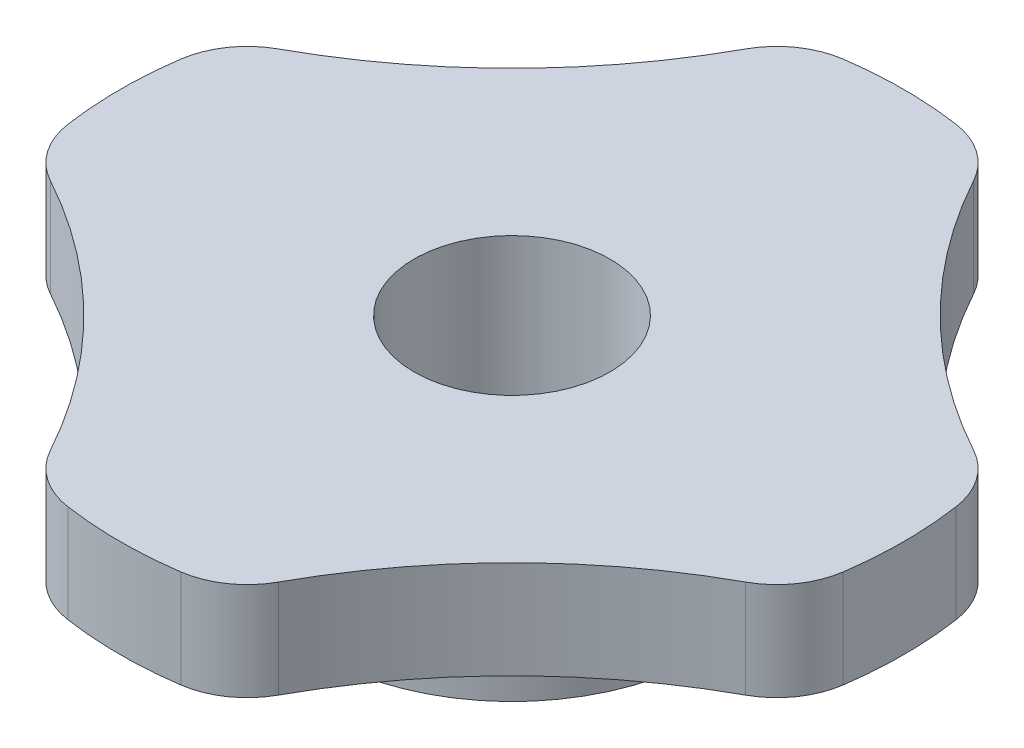
from build123d import *

# Parameters (mm, degrees)
SKETCH1_R           = 3.175
BOSS_EXTRUDE1_DEPTH = 3.175
BOSS_EXTRUDE2_START = -3.175
SKETCH1_3_R         = 3.175
BOSS_EXTRUDE2_DEPTH = 3.175
FILLET1_R           = 2.54


with BuildPart() as part:
    # Sketch1 → Boss-Extrude1 (new body)
    with BuildSketch(Plane(origin=(0, 0, 0), x_dir=(1, 0, 0), z_dir=(0, 1, 0))):
        with BuildLine():
            ThreePointArc((-3.175, 12.296722124), (-6.940246952, 6.940246952), (-12.296722124, 3.175))
            ThreePointArc((-12.296722124, 3.175), (-12.7, 0), (-12.296722124, -3.175))
            ThreePointArc((-12.296722124, -3.175), (-6.940246952, -6.940246952), (-3.175, -12.296722124))
            ThreePointArc((-3.175, -12.296722124), (0, -12.7), (3.175, -12.296722124))
            ThreePointArc((3.175, -12.296722124), (6.940246952, -6.940246952), (12.296722124, -3.175))
            ThreePointArc((12.296722124, -3.175), (12.7, 0), (12.296722124, 3.175))
            ThreePointArc((12.296722124, 3.175), (6.940246952, 6.940246952), (3.175, 12.296722124))
            ThreePointArc((3.175, 12.296722124), (0, 12.7), (-3.175, 12.296722124))
        make_face()
        Circle(SKETCH1_R, mode=Mode.SUBTRACT)
    extrude(amount=BOSS_EXTRUDE1_DEPTH)

    # Sketch1_3 → Boss-Extrude2 (add)
    with BuildSketch(Plane(origin=(0, 0, 0), x_dir=(1, 0, 0), z_dir=(0, 1, 0)).offset(BOSS_EXTRUDE2_START)):
        with BuildLine():
            ThreePointArc((3.175, 5.499261314), (0, 6.35), (-3.175, 5.499261314))
            ThreePointArc((-3.175, 5.499261314), (-4.490128061, 4.490128061), (-5.499261314, 3.175))
            ThreePointArc((-5.499261314, 3.175), (-6.35, 0), (-5.499261314, -3.175))
            ThreePointArc((-5.499261314, -3.175), (-4.490128061, -4.490128061), (-3.175, -5.499261314))
            ThreePointArc((-3.175, -5.499261314), (0, -6.35), (3.175, -5.499261314))
            ThreePointArc((3.175, -5.499261314), (4.490128061, -4.490128061), (5.499261314, -3.175))
            ThreePointArc((5.499261314, -3.175), (6.133628997, -1.643500936), (6.35, 0))
            ThreePointArc((6.35, 0), (6.133628997, 1.643500936), (5.499261314, 3.175))
            ThreePointArc((5.499261314, 3.175), (4.490128061, 4.490128061), (3.175, 5.499261314))
        make_face()
        Circle(SKETCH1_3_R, mode=Mode.SUBTRACT)
    extrude(amount=BOSS_EXTRUDE2_DEPTH)

    # Fillet1
    fillet1_edges = [part.edges().sort_by_distance(p)[0] for p in [
        (12.296722124, 1.5875, -3.175),
        (12.296722124, 1.5875, 3.175),
        (3.175, 1.5875, 12.296722124),
        (-3.175, 1.5875, 12.296722124),
        (-12.296722124, 1.5875, 3.175),
        (-12.296722124, 1.5875, -3.175),
        (3.175, 1.5875, -12.296722124),
        (-3.175, 1.5875, -12.296722124),
    ]]
    fillet(fillet1_edges, radius=FILLET1_R)


solid = part.part
